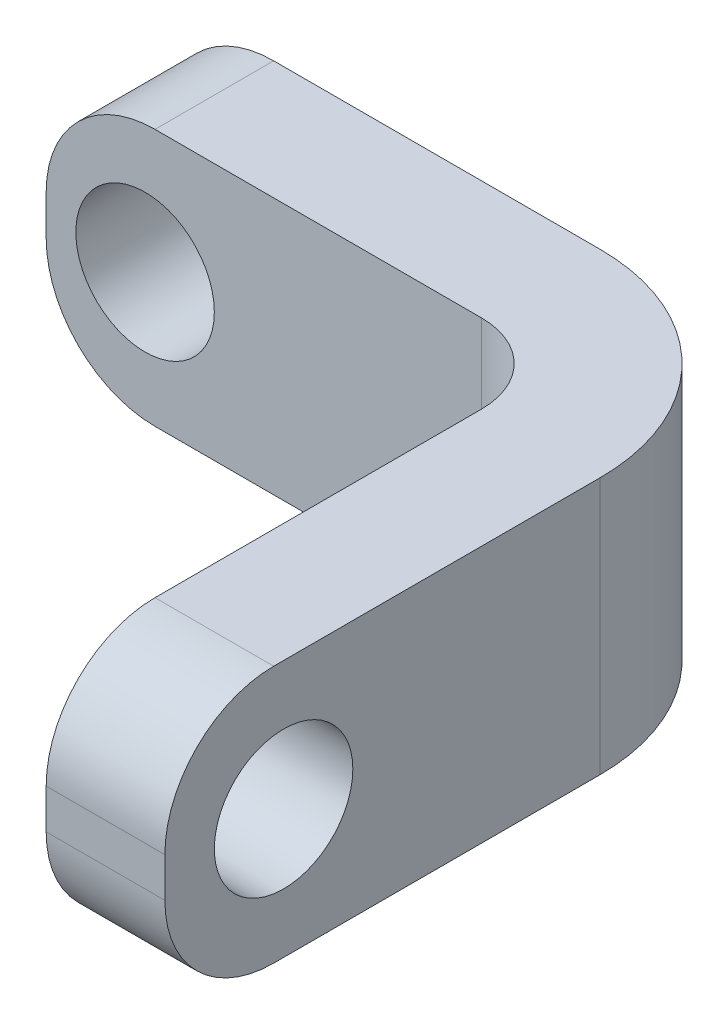
from build123d import *

# Parameters (mm, degrees)
ESQUISSE1_W             = 13
ESQUISSE1_H             = 6.5
ESQUISSE1_R             = 1.75
BOSS_EXTRU_1_DEPTH      = 3
ESQUISSE1_3_W           = 3
ESQUISSE1_3_H           = 6.5
BOSS_EXTRU_2_DEPTH      = 16
ENL_V_MAT_EXTRU_1_REACH = 24.86
ESQUISSE2_R             = 1.75
CONG_1_R                = 2.75
CONG_2_R                = 2
CONG_3_R                = 5


with BuildPart() as part:
    # Esquisse1 → Boss.-Extru.1 (new body)
    with BuildSketch(Plane.XY):
        with Locations((-1.5, 0)):
            Rectangle(ESQUISSE1_W, ESQUISSE1_H)
        with Locations((-5.5, 0)):
            Circle(ESQUISSE1_R, mode=Mode.SUBTRACT)
    extrude(amount=BOSS_EXTRU_1_DEPTH)

    # Esquisse1_3 → Boss.-Extru.2 (add)
    with BuildSketch(Plane.XY):
        with Locations((6.5, 0)):
            Rectangle(ESQUISSE1_3_W, ESQUISSE1_3_H)
    extrude(amount=BOSS_EXTRU_2_DEPTH)

    # Esquisse2 → Enlèv. mat.-Extru.1 (cut, up to next)
    with BuildSketch(Plane(origin=(8, 0, 0), x_dir=(0, 0, -1), z_dir=(1, 0, 0)), mode=Mode.PRIVATE) as enl_v_mat_extru_1_sk1:
        with Locations((-13, 0)):
            Circle(ESQUISSE2_R)
    enl_v_mat_extru_1_tool1 = extrude(enl_v_mat_extru_1_sk1.sketch, amount=-ENL_V_MAT_EXTRU_1_REACH, mode=Mode.PRIVATE) & part.part
    add(enl_v_mat_extru_1_tool1.solids().sort_by_distance((8, 0, 13))[0], mode=Mode.SUBTRACT)

    # Congé1
    cong_1_edges = [part.edges().sort_by_distance(p)[0] for p in [
        (6.5, -3.25, 16),
        (6.5, 3.25, 16),
        (-8, -3.25, 1.5),
        (-8, 3.25, 1.5),
    ]]
    fillet(cong_1_edges, radius=CONG_1_R)

    # Congé2
    cong_2_edges = [part.edges().sort_by_distance(p)[0] for p in [
        (5, 0, 3),
    ]]
    fillet(cong_2_edges, radius=CONG_2_R)

    # Congé3
    cong_3_edges = [part.edges().sort_by_distance(p)[0] for p in [
        (8, 0, 0),
    ]]
    fillet(cong_3_edges, radius=CONG_3_R)


solid = part.part
